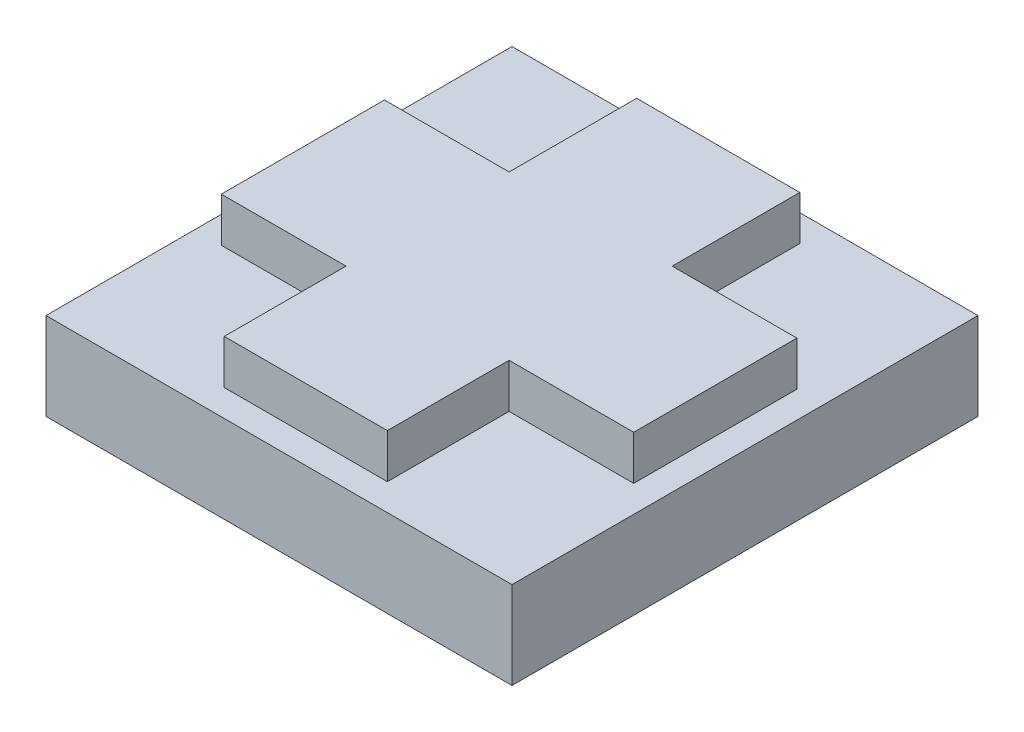
from build123d import *

# Parameters (mm, degrees)
SKETCH1_W           = 10.16
SKETCH1_H           = 10.16
BOSS_EXTRUDE1_DEPTH = 1.905
SKETCH2_W           = 3.556
SKETCH2_H           = 8.9916
BOSS_EXTRUDE4_DEPTH = 2.8702
SKETCH4_W           = 8.9916
SKETCH4_H           = 3.556
BOSS_EXTRUDE5_DEPTH = 2.8702


with BuildPart() as part:
    # Sketch1 → Boss-Extrude1 (new body)
    with BuildSketch(Plane(origin=(0, 0, 0), x_dir=(1, 0, 0), z_dir=(0, 1, 0))):
        with Locations((5.08, 5.08)):
            Rectangle(SKETCH1_W, SKETCH1_H)
    extrude(amount=BOSS_EXTRUDE1_DEPTH)

    # Sketch2 → Boss-Extrude4 (add)
    with BuildSketch(Plane(origin=(0, 0, 0), x_dir=(1, 0, 0), z_dir=(0, 1, 0))):
        with Locations((5.08, 5.08)):
            Rectangle(SKETCH2_W, SKETCH2_H)
    extrude(amount=BOSS_EXTRUDE4_DEPTH)

    # Sketch4 → Boss-Extrude5 (add)
    with BuildSketch(Plane(origin=(0, 0, 0), x_dir=(1, 0, 0), z_dir=(0, 1, 0))):
        with Locations((5.08, 5.0165)):
            Rectangle(SKETCH4_W, SKETCH4_H)
    extrude(amount=BOSS_EXTRUDE5_DEPTH)


solid = part.part
